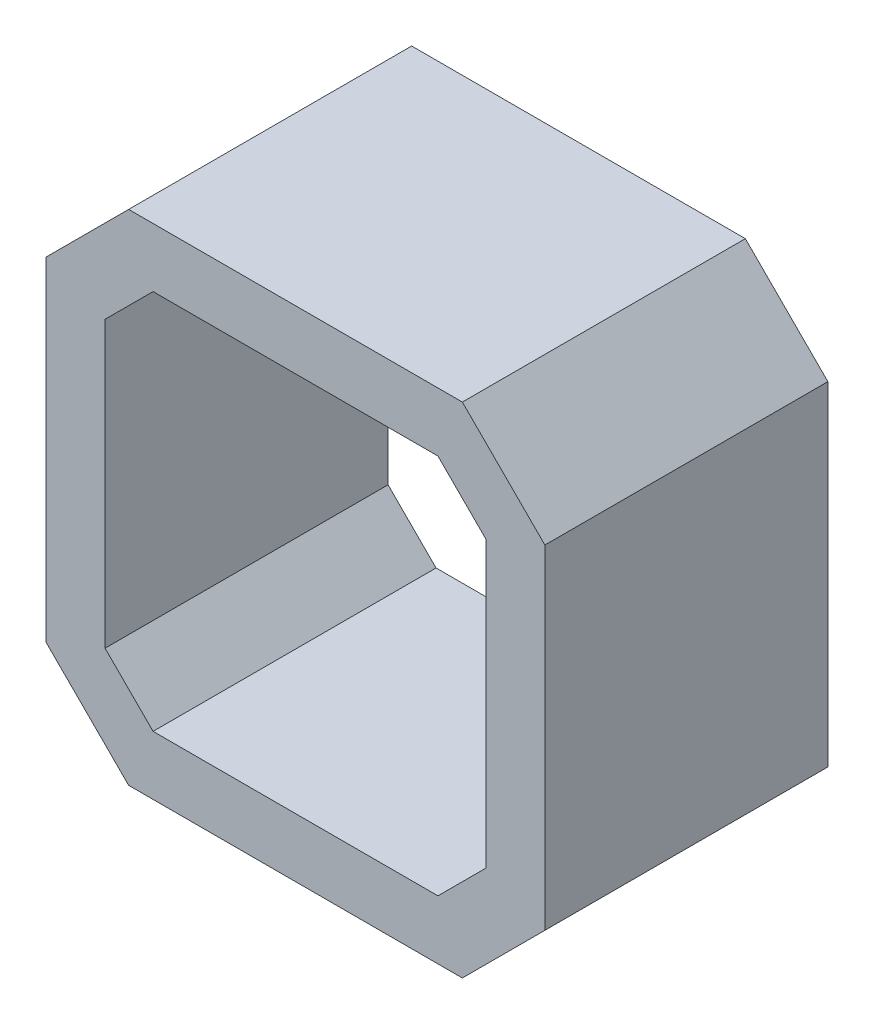
from build123d import *

# Parameters (mm, degrees)
Y_KSEKLIK_EKSTR_ZYON1_DEPTH = 24


with BuildPart() as part:
    # Çizim1 → Yükseklik-Ekstrüzyon1 (new body)
    with BuildSketch(Plane.XY):
        Polygon((-21.15, 14.15), (-14.15, 21.15), (14.15, 21.15), (21.15, 14.15), (21.15, -14.15), (14.15, -21.15), (-14.15, -21.15), (-21.15, -14.15), align=None)
        Polygon((-12.078932188, 16.15), (12.078932188, 16.15), (16.15, 12.078932188), (16.15, -12.078932188), (12.078932188, -16.15), (-12.078932188, -16.15), (-16.15, -12.078932188), (-16.15, 12.078932188), align=None, mode=Mode.SUBTRACT)
    extrude(amount=Y_KSEKLIK_EKSTR_ZYON1_DEPTH)


solid = part.part
